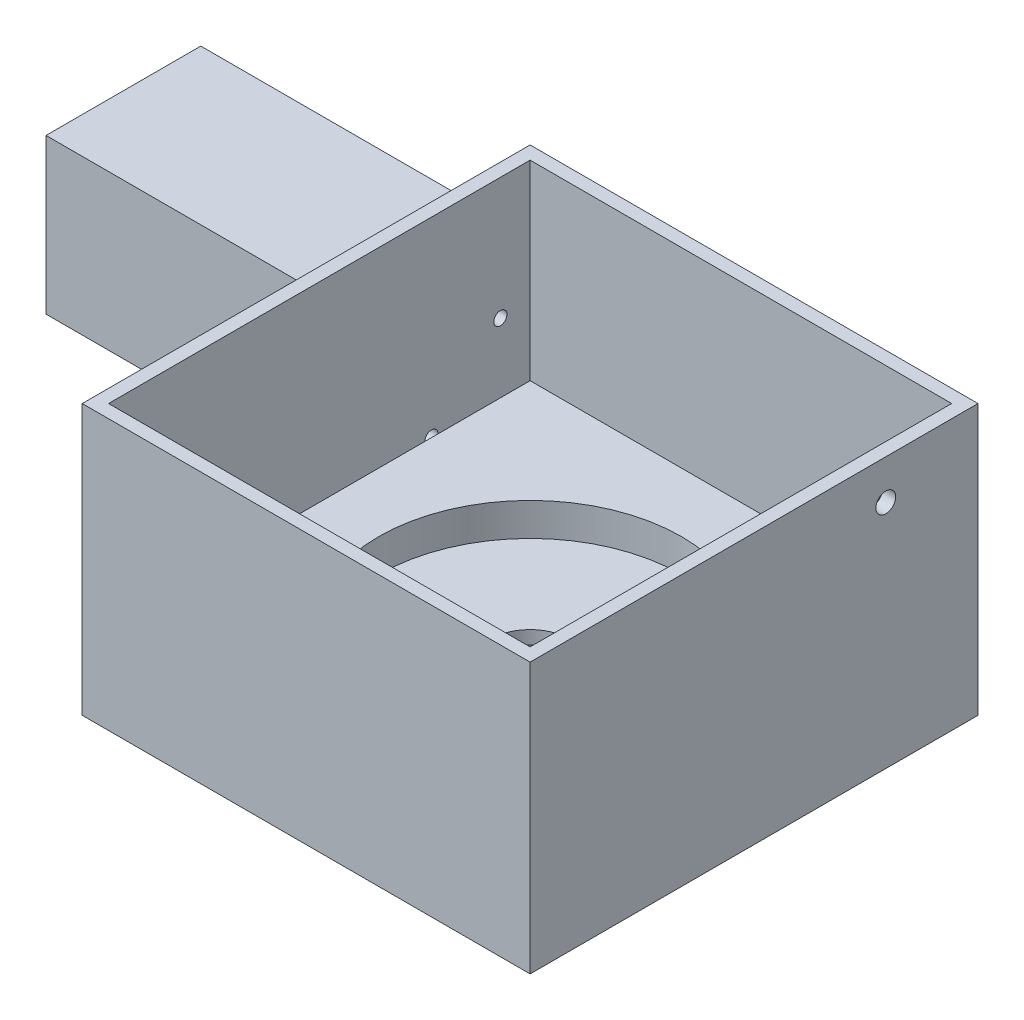
from build123d import *

# Parameters (mm, degrees)
SKETCH1_W           = 68
SKETCH1_H           = 68
BOSS_EXTRUDE1_DEPTH = 41
CUT_EXTRUDE1_START  = 41
SKETCH2_W           = 64
SKETCH2_H           = 64
CUT_EXTRUDE1_DEPTH  = 29
CUT_EXTRUDE4_START  = 12
SKETCH3_R           = 23
CUT_EXTRUDE4_DEPTH  = 5
CUT_EXTRUDE9_START  = 7
SKETCH5_R           = 6.05
CUT_EXTRUDE9_DEPTH  = 8
SKETCH6_R           = 10.5
CUT_EXTRUDE10_DEPTH = 5
SKETCH7_W           = 30
SKETCH7_H           = 30
SKETCH7_W_2         = 26
SKETCH7_H_2         = 26
CUT_EXTRUDE11_DEPTH = 2
SKETCH8_R           = 1.5
CUT_EXTRUDE12_DEPTH = 3
SKETCH9_W           = 23.5
SKETCH9_H           = 23.5
SKETCH9_R           = 5.6
BOSS_EXTRUDE4_DEPTH = 50
SKETCH11_R          = 1
CUT_EXTRUDE13_DEPTH = 52


with BuildPart() as part:
    # Sketch1 → Boss-Extrude1 (new body)
    with BuildSketch(Plane(origin=(0, 0, 0), x_dir=(1, 0, 0), z_dir=(0, 1, 0))):
        Rectangle(SKETCH1_W, SKETCH1_H)
    extrude(amount=BOSS_EXTRUDE1_DEPTH)

    # Sketch2 → Cut-Extrude1 (cut)
    with BuildSketch(Plane(origin=(0, 0, 0), x_dir=(1, 0, 0), z_dir=(0, 1, 0)).offset(CUT_EXTRUDE1_START)):
        Rectangle(SKETCH2_W, SKETCH2_H)
    extrude(amount=-CUT_EXTRUDE1_DEPTH, mode=Mode.SUBTRACT)

    # Sketch3 → Cut-Extrude4 (cut)
    with BuildSketch(Plane(origin=(0, 0, 0), x_dir=(1, 0, 0), z_dir=(0, 1, 0)).offset(CUT_EXTRUDE4_START)):
        Circle(SKETCH3_R)
    extrude(amount=-CUT_EXTRUDE4_DEPTH, mode=Mode.SUBTRACT)

    # Sketch5 → Cut-Extrude9 (cut, through all)
    with BuildSketch(Plane(origin=(0, 0, 0), x_dir=(1, 0, 0), z_dir=(0, 1, 0)).offset(CUT_EXTRUDE9_START)):
        Circle(SKETCH5_R)
    extrude(amount=-CUT_EXTRUDE9_DEPTH, mode=Mode.SUBTRACT)

    # Sketch6 → Cut-Extrude10 (cut)
    with BuildSketch(Plane.XZ):
        Circle(SKETCH6_R)
    extrude(amount=-CUT_EXTRUDE10_DEPTH, mode=Mode.SUBTRACT)

    # Sketch7 → Cut-Extrude11 (cut)
    with BuildSketch(Plane(origin=(0, 0, 0), x_dir=(-1, 0, 0), z_dir=(0, -1, 0))):
        Rectangle(SKETCH7_W, SKETCH7_H)
        Rectangle(SKETCH7_W_2, SKETCH7_H_2, mode=Mode.SUBTRACT)
    extrude(amount=-CUT_EXTRUDE11_DEPTH, mode=Mode.SUBTRACT)

    # Sketch8 → Cut-Extrude12 (cut, through all)
    with BuildSketch(Plane.ZY.offset(-32)):
        with Locations((-20, 35)):
            Circle(SKETCH8_R)
    extrude(amount=-CUT_EXTRUDE12_DEPTH, mode=Mode.SUBTRACT)

    # Sketch9 → Boss-Extrude4 (add)
    with BuildSketch(Plane.ZY.offset(34)):
        with Locations((-22.25, 17.25)):
            Rectangle(SKETCH9_W, SKETCH9_H)
        with Locations((-22.25, 17.25)):
            Circle(SKETCH9_R, mode=Mode.SUBTRACT)
    extrude(amount=BOSS_EXTRUDE4_DEPTH)

    # Sketch11 → Cut-Extrude13 (cut)
    with BuildSketch(Plane.ZY.offset(84)):
        with Locations((-27.482590181, 22.482590181)):
            Circle(SKETCH11_R)
        with Locations((-17.017409819, 12.017409819)):
            Circle(SKETCH11_R)
    extrude(amount=-CUT_EXTRUDE13_DEPTH, mode=Mode.SUBTRACT)


solid = part.part
